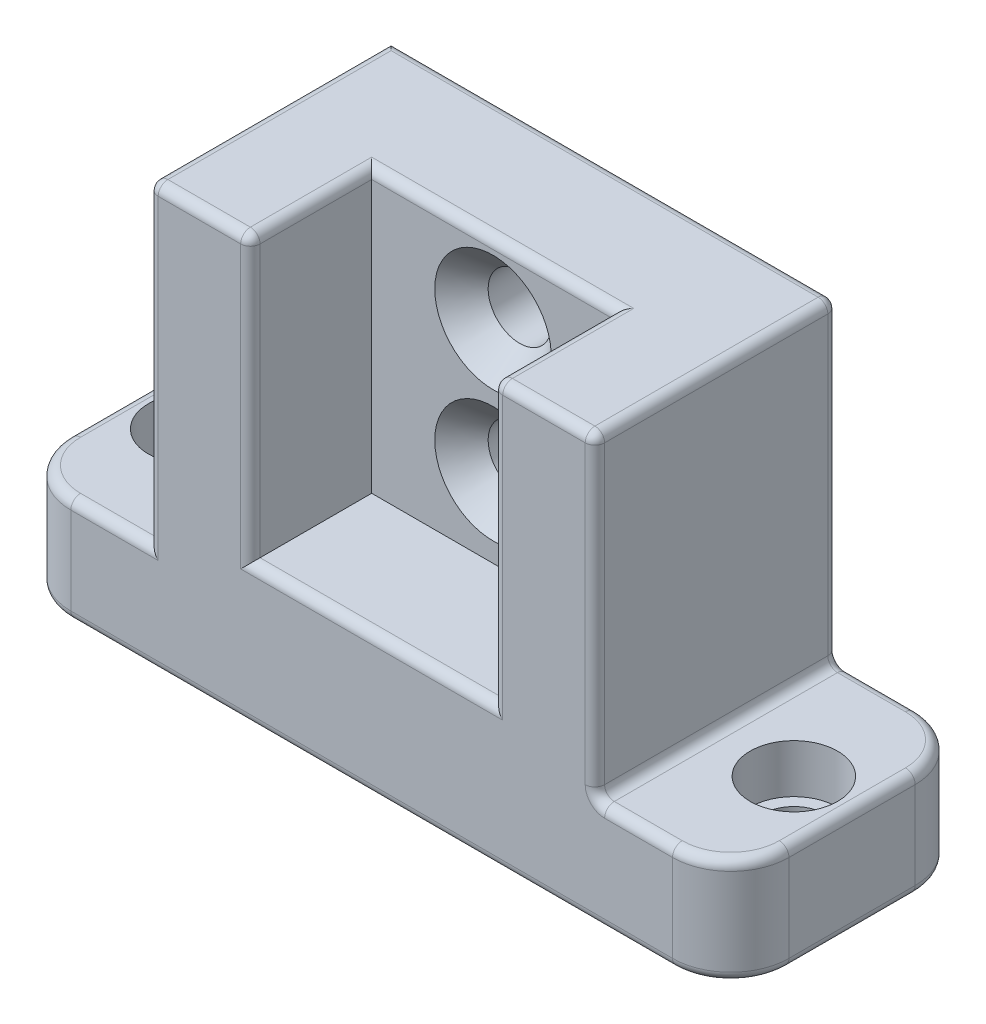
from build123d import *

# Parameters (mm, degrees)
BOSS_EXTRUDE1_DEPTH     = 50
SKETCH2_W               = 50
SKETCH2_H               = 25
CUT_EXTRUDE2_DEPTH      = 58
SKETCH3_R               = 6.5
CUT_EXTRUDE3_DEPTH      = 58
SKETCH3_3_R             = 9
SKETCH3_3_R_2           = 6.5
CUT_EXTRUDE4_DEPTH      = 10
SKETCH6_R               = 6.5
CUT_EXTRUDE5_DEPTH      = 19.5
CUT_EXTRUDE9_START      = -19.5
SKETCH6_3_R             = 6.5
CUT_EXTRUDE9_DEPTH      = 8.5
CUT_EXTRUDE9_DRAFT      = 45
MIRROR3_START           = -19.5
MIRROR3_COPY_1_SKETCH_R = 6.5
MIRROR3_COPY_1_DEPTH    = 8.5
MIRROR3_COPY_1_DRAFT    = 45
FILLET1_R               = 12
FILLET2_R               = 2


with BuildPart() as part:
    # Sketch1 → Boss-Extrude1 (new body)
    with BuildSketch(Plane.XY):
        Polygon((74, 0), (-74, 0), (-74, 22), (-46, 22), (-46, 87), (46, 87), (46, 22), (74, 22), align=None)
    extrude(amount=BOSS_EXTRUDE1_DEPTH)

    # Sketch2 → Cut-Extrude2 (cut)
    with BuildSketch(Plane(origin=(0, 87, 0), x_dir=(1, 0, 0), z_dir=(0, 1, 0))):
        with Locations((0, -37.5)):
            Rectangle(SKETCH2_W, SKETCH2_H)
    extrude(amount=-CUT_EXTRUDE2_DEPTH, mode=Mode.SUBTRACT)

    # Sketch3 → Cut-Extrude3 (cut)
    with BuildSketch(Plane(origin=(0, 22, 0), x_dir=(1, 0, 0), z_dir=(0, 1, 0))):
        with Locations((62, -25)):
            Circle(SKETCH3_R)
    cut_extrude3 = extrude(amount=-CUT_EXTRUDE3_DEPTH, mode=Mode.SUBTRACT)

    # Sketch3_3 → Cut-Extrude4 (cut)
    with BuildSketch(Plane(origin=(0, 22, 0), x_dir=(1, 0, 0), z_dir=(0, 1, 0))):
        with Locations((62, -25)):
            Circle(SKETCH3_3_R)
        with Locations((62, -25)):
            Circle(SKETCH3_3_R_2, mode=Mode.SUBTRACT)
    cut_extrude4 = extrude(amount=-CUT_EXTRUDE4_DEPTH, mode=Mode.SUBTRACT)

    # Mirror2: Cut-Extrude3, Cut-Extrude4 across plane
    add(cut_extrude3.mirror(Plane(origin=(0, 0, 0), x_dir=(0, 0, 1), z_dir=(1, 0, 0))), mode=Mode.SUBTRACT)
    add(cut_extrude4.mirror(Plane(origin=(0, 0, 0), x_dir=(0, 0, 1), z_dir=(1, 0, 0))), mode=Mode.SUBTRACT)

    # Sketch6 → Cut-Extrude5 (cut)
    with BuildSketch(Plane(origin=(0, 0, 0), x_dir=(-1, 0, 0), z_dir=(0, 0, -1))):
        with Locations((0, 72)):
            Circle(SKETCH6_R)
    cut_extrude5 = extrude(amount=-CUT_EXTRUDE5_DEPTH, mode=Mode.SUBTRACT)


with BuildPart() as cut_extrude9_tool:
    # Sketch6_3 → Cut-Extrude9 (with draft: the straight prism first)
    with BuildSketch(Plane(origin=(0, 0, 0), x_dir=(-1, 0, 0), z_dir=(0, 0, -1)).offset(CUT_EXTRUDE9_START)):
        with Locations((0, 72)):
            Circle(SKETCH6_3_R)
    extrude(amount=-CUT_EXTRUDE9_DEPTH)
    # Cut-Extrude9: the draft: its side faces are tilted about the plane it starts from
    cut_extrude9_sides = [cut_extrude9_tool.faces().sort_by_distance(p)[0] for p in [
        (6.5, 72, 23.75),
    ]]
    draft(cut_extrude9_sides, Plane(origin=(0, 0, 0), x_dir=(-1, 0, 0), z_dir=(0, 0, -1)).offset(CUT_EXTRUDE9_START), CUT_EXTRUDE9_DRAFT)


with BuildPart() as part_1:
    add(part.part)

    # Cut-Extrude9: cut by cut_extrude9_tool
    add(cut_extrude9_tool.part, mode=Mode.SUBTRACT)

    # Mirror3: Cut-Extrude5 across plane
    add(cut_extrude5.mirror(Plane.ZX.offset(58.5)), mode=Mode.SUBTRACT)


with BuildPart() as mirror3_copy_1_tool:
    # Mirror3 copy 1 sketch → Mirror3 copy 1 (with draft: the straight prism first)
    with BuildSketch(Plane(origin=(0, 117, 0), x_dir=(-1, 0, 0), z_dir=(0, 0, -1)).offset(MIRROR3_START)):
        with Locations((0, -72)):
            Circle(MIRROR3_COPY_1_SKETCH_R)
    extrude(amount=-MIRROR3_COPY_1_DEPTH)
    # Mirror3 copy 1: the draft: its side faces are tilted about the plane it starts from
    mirror3_copy_1_sides = [mirror3_copy_1_tool.faces().sort_by_distance(p)[0] for p in [
        (6.5, 45, 23.75),
    ]]
    draft(mirror3_copy_1_sides, Plane(origin=(0, 117, 0), x_dir=(-1, 0, 0), z_dir=(0, 0, -1)).offset(MIRROR3_START), MIRROR3_COPY_1_DRAFT)


with BuildPart() as part_2:
    add(part_1.part)

    # Mirror3 copy 1: cut by mirror3_copy_1_tool
    add(mirror3_copy_1_tool.part, mode=Mode.SUBTRACT)

    # Fillet1
    fillet1_edges = [part_2.edges().sort_by_distance(p)[0] for p in [
        (-74, 11, 0),
        (-74, 11, 50),
        (74, 11, 0),
        (74, 11, 50),
    ]]
    fillet(fillet1_edges, radius=FILLET1_R)

    # Fillet2
    fillet2_edges = [part_2.edges().sort_by_distance(p)[0] for p in [
        (54, 22, 0),
        (70.485281374, 22, 3.514718626),
        (74, 22, 25),
        (70.485281374, 22, 46.485281374),
        (-70.485281374, 0, 46.485281374),
        (-74, 0, 25),
        (-70.485281374, 0, 3.514718626),
        (0, 0, 0),
        (70.485281374, 0, 3.514718626),
        (74, 0, 25),
        (70.485281374, 0, 46.485281374),
        (-54, 22, 0),
        (-70.485281374, 22, 3.514718626),
        (-74, 22, 25),
        (-70.485281374, 22, 46.485281374),
        (46, 22, 25),
        (46, 54.5, 0),
        (-46, 54.5, 50),
        (-25, 58, 50),
        (0, 29, 50),
        (25, 58, 50),
        (46, 54.5, 50),
        (54, 22, 50),
        (0, 0, 50),
        (-54, 22, 50),
        (0, 87, 25),
        (-25, 87, 37.5),
        (-35.5, 87, 50),
        (-46, 87, 25),
        (0, 87, 0),
        (46, 87, 25),
        (35.5, 87, 50),
        (25, 87, 37.5),
    ]]
    fillet(fillet2_edges, radius=FILLET2_R)


solid = part_2.part
